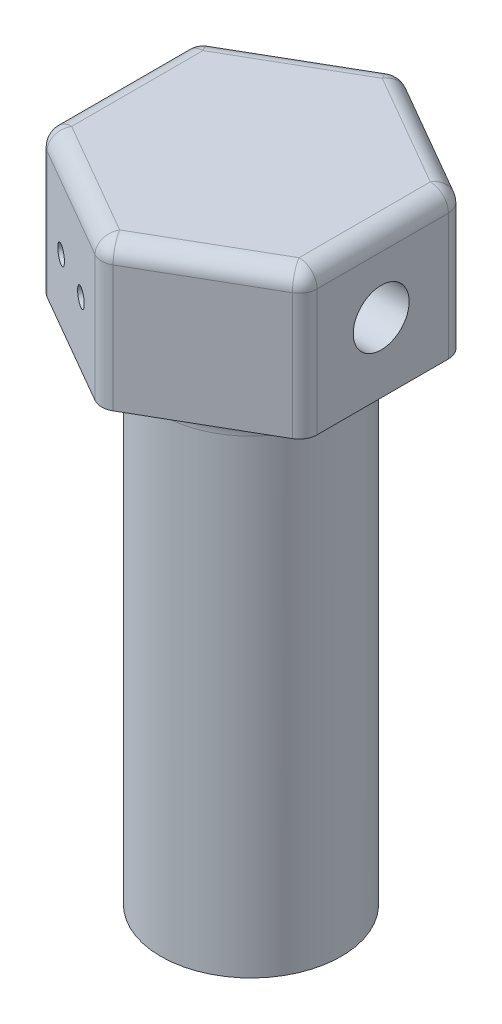
from build123d import *

# Parameters (mm, degrees)
BOSS_EXTRUDE1_DEPTH     = 8
SKETCH2_R               = 5
BOSS_EXTRUDE2_DEPTH     = 28
FILLET1_R               = 2
SKETCH3_R               = 1.55
CUT_EXTRUDE1_DEPTH      = 33.683533061
FILLET2_R               = 1
CUT_EXTRUDE3_START      = -4
SKETCH5_R               = 1.6
CUT_EXTRUDE3_DEPTH      = 4
SKETCH6_R               = 0.5
CUT_EXTRUDE4_DEPTH      = 0.5
CUT_EXTRUDE5_REACH      = 32.096
CUT_EXTRUDE5_END_RADIUS = 1.55
SKETCH7_R               = 1


with BuildPart() as part:
    # Sketch1 → Boss-Extrude1 (new body)
    with BuildSketch(Plane(origin=(0, 0, 0), x_dir=(1, 0, 0), z_dir=(0, 1, 0))):
        Polygon((7.3, -4.214656965), (7.3, 4.214656965), (0, 8.42931393), (-7.3, 4.214656965), (-7.3, -4.214656965), (0, -8.42931393), align=None)
    extrude(amount=BOSS_EXTRUDE1_DEPTH)

    # Sketch2 → Boss-Extrude2 (add)
    with BuildSketch(Plane.XZ):
        Circle(SKETCH2_R)
        with BuildLine():
            Line((-1.15, 1.112429773), (-1.15, -1.112429773))
            ThreePointArc((-1.15, -1.112429773), (1.6, 0), (-1.15, 1.112429773))
        make_face(mode=Mode.SUBTRACT)
    extrude(amount=BOSS_EXTRUDE2_DEPTH)

    # Fillet1
    fillet1_edges = [part.edges().sort_by_distance(p)[0] for p in [
        (-5, 0, 0),
    ]]
    fillet(fillet1_edges, radius=FILLET1_R)

    # Sketch3 → Cut-Extrude1 (cut, through all)
    with BuildSketch(Plane(origin=(7.3, 0, 0), x_dir=(0, 0, -1), z_dir=(1, 0, 0))):
        with Locations((-0.085343035, 3.85)):
            Circle(SKETCH3_R)
    extrude(amount=-CUT_EXTRUDE1_DEPTH, mode=Mode.SUBTRACT)

    # Fillet2
    fillet2_edges = [part.edges().sort_by_distance(p)[0] for p in [
        (-3.65, 8, 6.321985448),
        (-7.3, 8, 0),
        (-3.65, 8, -6.321985448),
        (3.65, 8, -6.321985448),
        (7.3, 8, 0),
        (3.65, 8, 6.321985448),
        (-7.3, 4, -4.214656965),
        (0, 4, -8.42931393),
        (7.3, 4, -4.214656965),
        (7.3, 4, 4.214656965),
        (0, 4, 8.42931393),
        (-7.3, 4, 4.214656965),
    ]]
    fillet(fillet2_edges, radius=FILLET2_R)

    # Sketch5 → Cut-Extrude3 (cut)
    with BuildSketch(Plane.XZ.offset(28).offset(CUT_EXTRUDE3_START)):
        Circle(SKETCH5_R)
    extrude(amount=CUT_EXTRUDE3_DEPTH, mode=Mode.SUBTRACT)

    # Sketch6 → Cut-Extrude4 (cut)
    with BuildSketch(Plane(origin=(-3.65, 0, 6.321985448), x_dir=(0.8660254037844386, 0, 0.5000000000000001), z_dir=(-0.5000000000000001, 0, 0.8660254037844386))):
        with Locations((-1.5, 3.5)):
            Circle(SKETCH6_R)
        with Locations((1.5, 3.5)):
            Circle(SKETCH6_R)
    extrude(amount=-CUT_EXTRUDE4_DEPTH, mode=Mode.SUBTRACT)

    # Cut-Extrude5: up to this cylinder (the profile starts outside it)
    cut_extrude5_end = Plane(origin=(0, 3.85, 0.085343035), z_dir=(1, 0, 0)) * Cylinder(CUT_EXTRUDE5_END_RADIUS, 68.292, mode=Mode.PRIVATE)
    # Sketch7 → Cut-Extrude5 (cut, up to the surface)
    with BuildSketch(Plane.XZ, mode=Mode.PRIVATE) as cut_extrude5_sk1:
        Circle(SKETCH7_R)
    cut_extrude5_tool1 = extrude(cut_extrude5_sk1.sketch, amount=-CUT_EXTRUDE5_REACH, mode=Mode.PRIVATE) - cut_extrude5_end
    add(cut_extrude5_tool1.solids().sort_by_distance((0, 0, 0))[0], mode=Mode.SUBTRACT)


solid = part.part
